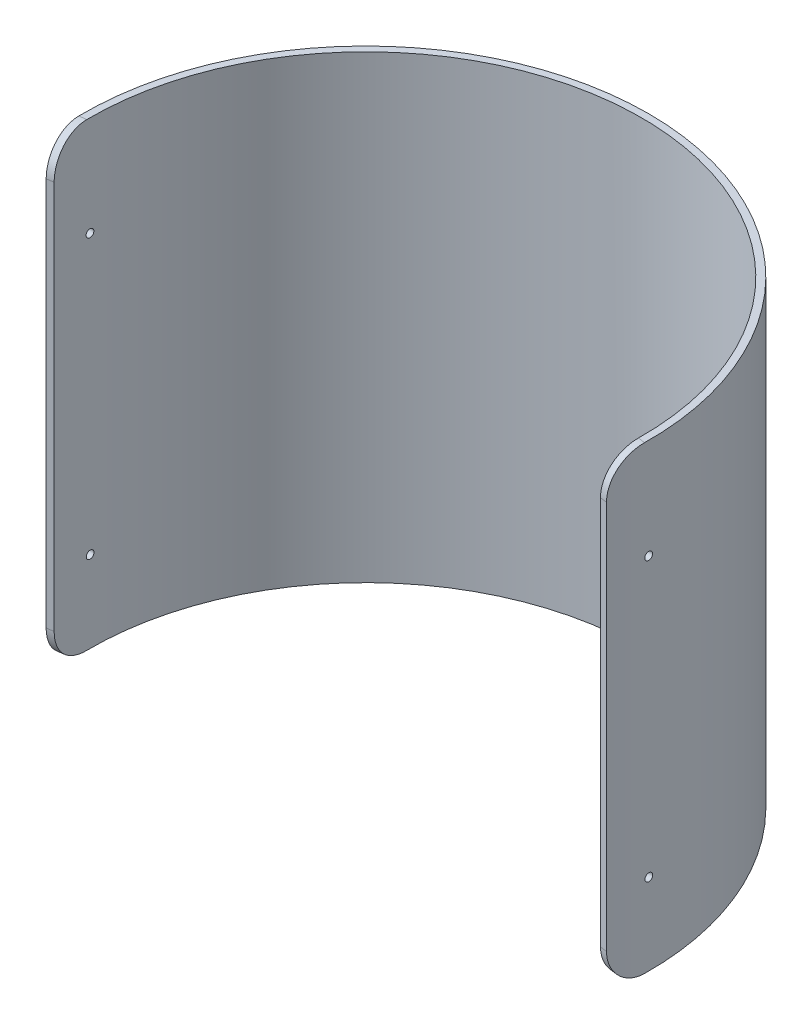
from build123d import *

# Parameters (mm, degrees)
SKETCH1_R               = 101.6
SKETCH1_R_2             = 99.06
BOSS_EXTRUDE1_DEPTH     = 165.1
CUT_EXTRUDE1_DEPTH      = 165.1
FILLET1_R               = 12.7
SKETCH3_R               = 1.397
CUT_EXTRUDE2_DEPTH      = 219.867837001
CUT_EXTRUDE2_DEPTH_BACK = 219.867837001
SKETCH4_R               = 9.525
CUT_EXTRUDE3_DEPTH      = 219.867837003


with BuildPart() as part:
    # Sketch1 → Boss-Extrude1 (new body)
    with BuildSketch(Plane(origin=(0, 0, 0), x_dir=(1, 0, 0), z_dir=(0, 1, 0))):
        with Locations(Location((0, 0, 0), (0, 0, 270))):
            Circle(SKETCH1_R)
        with Locations(Location((0, 0, 0), (0, 0, 270))):
            Circle(SKETCH1_R_2, mode=Mode.SUBTRACT)
    extrude(amount=BOSS_EXTRUDE1_DEPTH)

    # Sketch2 → Cut-Extrude1 (cut)
    with BuildSketch(Plane(origin=(0, 0, 0), x_dir=(1, 0, 0), z_dir=(0, 1, 0))):
        Polygon((571.962381958, -80.384070579), (100.611235784, -14.139987058), (0, 0), (-100.611235784, -14.139987058), (-571.962381958, -80.384070579), (-571.962381958, -1032.350838067), (571.962381958, -1032.350838067), align=None)
    extrude(amount=CUT_EXTRUDE1_DEPTH, mode=Mode.SUBTRACT)

    # Fillet1
    fillet1_edges = [part.edges().sort_by_distance(p)[0] for p in [
        (-99.353595337, 0, 13.963237219),
        (99.353595337, 165.1, 13.963237219),
        (-99.353595337, 165.1, 13.963237219),
        (99.353595337, 0, 13.963237219),
    ]]
    fillet(fillet1_edges, radius=FILLET1_R)

    # Sketch3 → Cut-Extrude2 (cut, two sides)
    with BuildSketch(Plane(origin=(0, 0, 0), x_dir=(0, 0, -1), z_dir=(1, 0, 0))) as cut_extrude2_sk:
        with Locations((0.084012942, 29.1846)):
            Circle(SKETCH3_R)
        with Locations((0.022897636, 129.159100035)):
            Circle(SKETCH3_R)
    extrude(amount=CUT_EXTRUDE2_DEPTH, mode=Mode.SUBTRACT)
    extrude(cut_extrude2_sk.sketch, amount=-CUT_EXTRUDE2_DEPTH_BACK, mode=Mode.SUBTRACT)

    # Sketch4 → Cut-Extrude3 (cut, through all)
    with BuildSketch(Plane.XY):
        with Locations((0, 20.32)):
            Circle(SKETCH4_R)
    extrude(amount=-CUT_EXTRUDE3_DEPTH, mode=Mode.SUBTRACT)


solid = part.part
